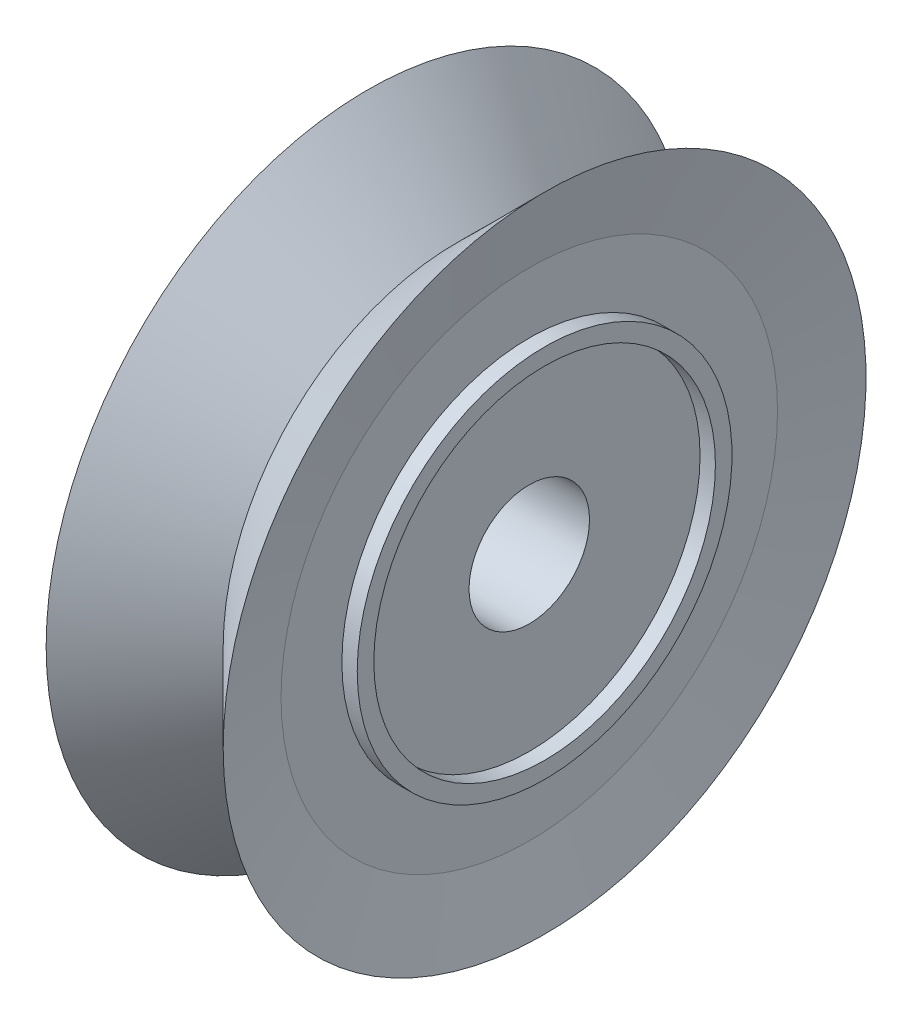
from build123d import *

# Parameters (mm, degrees)
SKETCH2_R          = 1.160779638
CUT_EXTRUDE1_DEPTH = 7.62


with BuildPart() as part:
    # Sketch1 → Revolve1 (revolve)
    with BuildSketch(Plane(origin=(0, 0, 0), x_dir=(1, 0, 0), z_dir=(0, 1, 0))):
        Polygon((-23.567795766, 7.367626397), (-25.274044429, 9.07387506), (-26.980293092, 7.367626397), (-26.684604524, 8.778186492), (-26.684604524, 9.951033697), (-26.980293092, 9.951033697), (-26.980293092, 10.270846758), (-26.684604524, 10.270846758), (-26.684604524, 13.5627756), (-23.863484334, 13.5627756), (-23.863484334, 10.270846758), (-23.567795766, 10.270846758), (-23.567795766, 9.951033697), (-23.863484334, 9.951033697), (-23.863484334, 8.778186492), align=None)
    revolve(axis=Axis((-23.863484334, 0, -13.5627756), (1, 0, 0)))

    # Sketch2 → Cut-Extrude1 (cut)
    with BuildSketch(Plane.ZY.offset(26.684604524)):
        with Locations((-13.5627756, 0)):
            Circle(SKETCH2_R)
    extrude(amount=-CUT_EXTRUDE1_DEPTH, mode=Mode.SUBTRACT)


solid = part.part
